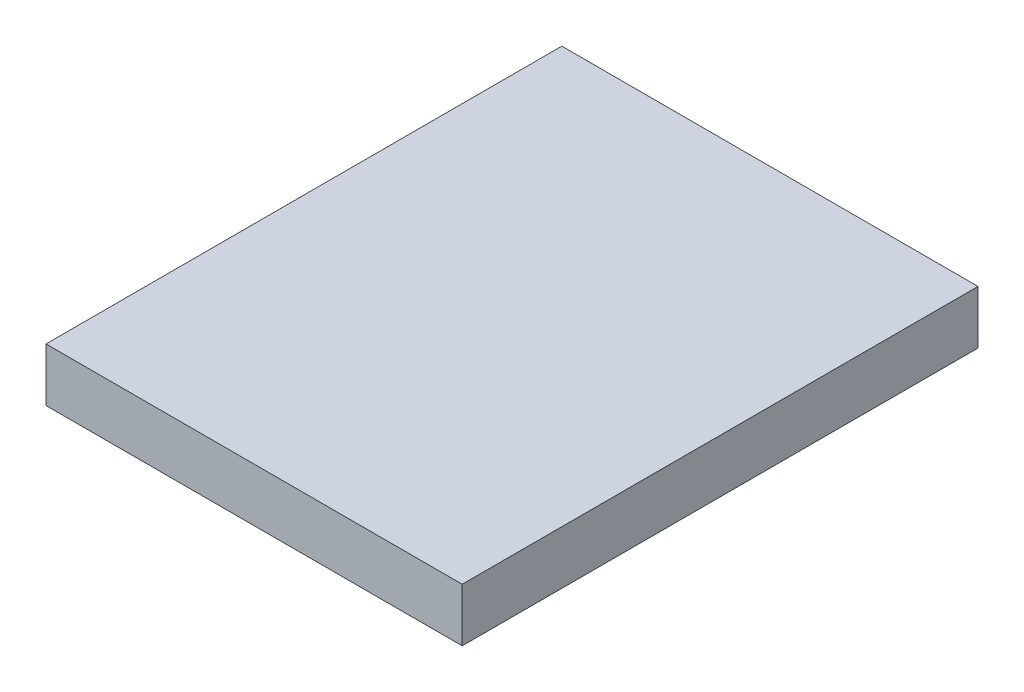
from build123d import *

# Parameters (mm, degrees)
BOSS_EXTRUDE1_DEPTH   = 3
BOSS_EXTRUDE1_2_DEPTH = 3
SKETCH1_W             = 23.4
SKETCH1_H             = 29
BOSS_EXTRUDE1_3_DEPTH = 3
SKETCH5_R             = 1.44
CUT_EXTRUDE3_DEPTH    = 10
CUT_EXTRUDE4_DEPTH    = 10
SKETCH9_R             = 3.026992654
BOSS_EXTRUDE3_DEPTH   = 3


with BuildPart() as part:
    # Sketch1 → Boss-Extrude1 (new body)
    with BuildSketch(Plane(origin=(0, 0, 0), x_dir=(1, 0, 0), z_dir=(0, 1, 0))):
        with BuildLine():
            add(Edge.make_bspline(
                [(19.180993887, -14.242526212), (19.80083761, -12.341053413), (17.899318471, -11.721194585), (17.279474749, -13.622667384), (16.659631026, -15.524140184), (18.561150164, -16.143999012), (19.180993887, -14.242526212)],
                knots=[0, 0, 0, 0, 0.5, 0.5, 0.5, 1, 1, 1, 1], degree=3, weights=[1, 0.333333333, 0.333333333, 1, 0.333333333, 0.333333333, 1]))
        make_face()
    extrude(amount=BOSS_EXTRUDE1_DEPTH)


with BuildPart() as body_2:
    # Sketch1 → Boss-Extrude1 2 (new body)
    with BuildSketch(Plane(origin=(0, 0, 0), x_dir=(1, 0, 0), z_dir=(0, 1, 0))):
        with BuildLine():
            add(Edge.make_bspline(
                [(22.488505608, -4.096188772), (23.108349331, -2.194715972), (21.206830193, -1.574857144), (20.58698647, -3.476329943), (19.967142747, -5.377802743), (21.868661885, -5.997661571), (22.488505608, -4.096188772)],
                knots=[0, 0, 0, 0, 0.5, 0.5, 0.5, 1, 1, 1, 1], degree=3, weights=[1, 0.333333333, 0.333333333, 1, 0.333333333, 0.333333333, 1]))
        make_face()
    extrude(amount=BOSS_EXTRUDE1_2_DEPTH)


with BuildPart() as body_3:
    # Sketch1 → Boss-Extrude1 3 (new body)
    with BuildSketch(Plane(origin=(0, 0, 0), x_dir=(1, 0, 0), z_dir=(0, 1, 0))):
        Rectangle(SKETCH1_W, SKETCH1_H)
    extrude(amount=BOSS_EXTRUDE1_3_DEPTH)

    # Sketch5 → Cut-Extrude3 (cut)
    with BuildSketch(Plane.XZ):
        with Locations(Location((-2.145634177, 3.61037734, 0), (0, 0, 270))):
            Circle(SKETCH5_R)
    extrude(amount=-CUT_EXTRUDE3_DEPTH, mode=Mode.SUBTRACT)

    # Sketch9 → Boss-Extrude3 (add)
    with BuildSketch(Plane(origin=(0, 3, 0), x_dir=(1, 0, 0), z_dir=(0, 1, 0))):
        with Locations((-2.145634177, -3.61037734)):
            Circle(SKETCH9_R)
    extrude(amount=-BOSS_EXTRUDE3_DEPTH)


with BuildPart() as cut_extrude4_tool:
    # Sketch7 → Cut-Extrude4 (new body)
    with BuildSketch(Plane(origin=(0, 3, 0), x_dir=(1, 0, 0), z_dir=(0, 1, 0))):
        with BuildLine():
            add(Edge.make_bspline(
                [(19.180993887, -14.242526212), (19.80083761, -12.341053413), (17.899318471, -11.721194585), (17.279474749, -13.622667384), (16.659631026, -15.524140184), (18.561150164, -16.143999012), (19.180993887, -14.242526212)],
                knots=[0, 0, 0, 0, 0.5, 0.5, 0.5, 1, 1, 1, 1], degree=3, weights=[1, 0.333333333, 0.333333333, 1, 0.333333333, 0.333333333, 1]))
        make_face()
        with BuildLine():
            add(Edge.make_bspline(
                [(22.488505608, -4.096188772), (23.108349331, -2.194715972), (21.206830193, -1.574857144), (20.58698647, -3.476329943), (19.967142747, -5.377802743), (21.868661885, -5.997661571), (22.488505608, -4.096188772)],
                knots=[0, 0, 0, 0, 0.5, 0.5, 0.5, 1, 1, 1, 1], degree=3, weights=[1, 0.333333333, 0.333333333, 1, 0.333333333, 0.333333333, 1]))
        make_face()
    extrude(amount=-CUT_EXTRUDE4_DEPTH)


with BuildPart() as part_1:
    add(part.part)

    # Cut-Extrude4: cut by cut_extrude4_tool
    add(cut_extrude4_tool.part, mode=Mode.SUBTRACT)


with BuildPart() as body_2_1:
    add(body_2.part)

    # Cut-Extrude4: cut by cut_extrude4_tool
    add(cut_extrude4_tool.part, mode=Mode.SUBTRACT)


solid = body_3.part
